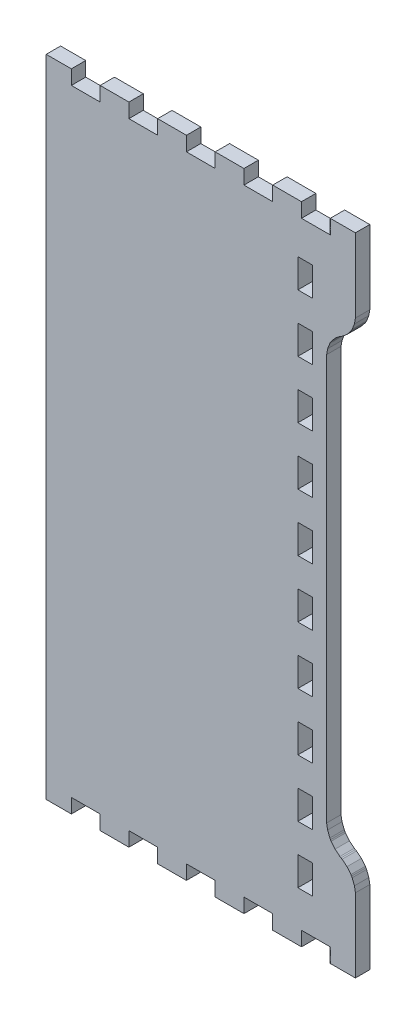
from build123d import *

# Parameters (mm, degrees)
BOSS_EXTRUDE1_DEPTH = 5.715


with BuildPart() as part:
    # Model → Boss-Extrude1 (new body)
    with BuildSketch(Plane.XY):
        Polygon((1156.43152, 23.2006394), (1166.42388, 23.2006394), (1166.42388, 28.91536), (1177.85388, 28.91536), (1177.85388, 23.2006394), (1189.28388, 23.2006394), (1189.28388, 28.91536), (1200.71388, 28.91536), (1200.71388, 23.2006394), (1212.14388, 23.2006394), (1212.14388, 28.91536), (1223.57388, 28.91536), (1223.57388, 23.2006394), (1235.00388, 23.2006394), (1235.00388, 28.91536), (1246.43388, 28.91536), (1246.43388, 23.2006394), (1257.86388, 23.2006394), (1257.86388, 28.91536), (1269.29388, 28.91536), (1269.29388, 23.2006394), (1279.28878, 23.2006394), (1279.28878, 51.775868), (1279.28878, 52.515516), (1278.90016, 54.734206), (1278.00862, 57.056274), (1277.75716, 57.49036), (1277.50824, 57.925716), (1275.94106, 59.857894), (1274.00812, 61.423296), (1273.57378, 61.673994), (1273.13944, 61.924946), (1271.2065, 63.491872), (1269.63932, 65.423796), (1269.3904, 65.857882), (1269.13894, 66.293238), (1268.24994, 68.615306), (1267.85878, 70.833996), (1267.85878, 71.572628), (1267.85878, 231.25811), (1267.85878, 231.998266), (1268.24994, 234.216956), (1269.13894, 236.539024), (1269.3904, 236.972856), (1269.63932, 237.408466), (1271.2065, 239.34039), (1273.13944, 240.906046), (1273.57378, 241.156744), (1274.00812, 241.407696), (1275.94106, 242.974368), (1277.50824, 244.906546), (1277.75716, 245.340378), (1278.00862, 245.775988), (1278.90016, 248.098056), (1279.28878, 250.316746), (1279.28878, 251.055124), (1279.28878, 279.63114), (1269.29388, 279.63114), (1269.29388, 273.91614), (1257.86388, 273.91614), (1257.86388, 279.63114), (1246.43388, 279.63114), (1246.43388, 273.91614), (1235.00388, 273.91614), (1235.00388, 279.63114), (1223.57388, 279.63114), (1223.57388, 273.91614), (1212.14388, 273.91614), (1212.14388, 279.63114), (1200.71388, 279.63114), (1200.71388, 273.91614), (1189.28388, 273.91614), (1189.28388, 279.63114), (1177.85388, 279.63114), (1177.85388, 273.91614), (1166.42388, 273.91614), (1166.42388, 279.63114), (1156.43152, 279.63114), align=None)
        Polygon((1262.14378, 48.545496), (1262.14378, 42.83075), (1256.43132, 42.83075), (1256.43132, 54.260496), (1262.14378, 54.260496), align=None, mode=Mode.SUBTRACT)
        Polygon((1262.14378, 71.40575), (1262.14378, 65.691004), (1256.43132, 65.691004), (1256.43132, 77.120496), (1262.14378, 77.120496), align=None, mode=Mode.SUBTRACT)
        Polygon((1262.14378, 94.266004), (1262.14378, 88.549988), (1256.43132, 88.549988), (1256.43132, 99.98075), (1262.14378, 99.98075), align=None, mode=Mode.SUBTRACT)
        Polygon((1262.14378, 117.124988), (1262.14378, 111.410496), (1256.43132, 111.410496), (1256.43132, 122.841004), (1262.14378, 122.841004), align=None, mode=Mode.SUBTRACT)
        Polygon((1262.14378, 139.985496), (1262.14378, 134.270496), (1256.43132, 134.270496), (1256.43132, 145.699988), (1262.14378, 145.699988), align=None, mode=Mode.SUBTRACT)
        Polygon((1262.14378, 162.845496), (1262.14378, 157.13075), (1256.43132, 157.13075), (1256.43132, 168.560496), (1262.14378, 168.560496), align=None, mode=Mode.SUBTRACT)
        Polygon((1262.14378, 185.70575), (1262.14378, 179.991004), (1256.43132, 179.991004), (1256.43132, 191.420496), (1262.14378, 191.420496), align=None, mode=Mode.SUBTRACT)
        Polygon((1262.14378, 208.566004), (1262.14378, 202.849988), (1256.43132, 202.849988), (1256.43132, 214.28075), (1262.14378, 214.28075), align=None, mode=Mode.SUBTRACT)
        Polygon((1262.14378, 231.424988), (1262.14378, 225.710496), (1256.43132, 225.710496), (1256.43132, 237.141004), (1262.14378, 237.141004), align=None, mode=Mode.SUBTRACT)
        Polygon((1262.14378, 254.28448), (1262.14378, 248.570496), (1256.43132, 248.570496), (1256.43132, 259.99948), (1262.14378, 259.99948), align=None, mode=Mode.SUBTRACT)
    extrude(amount=BOSS_EXTRUDE1_DEPTH)


solid = part.part
